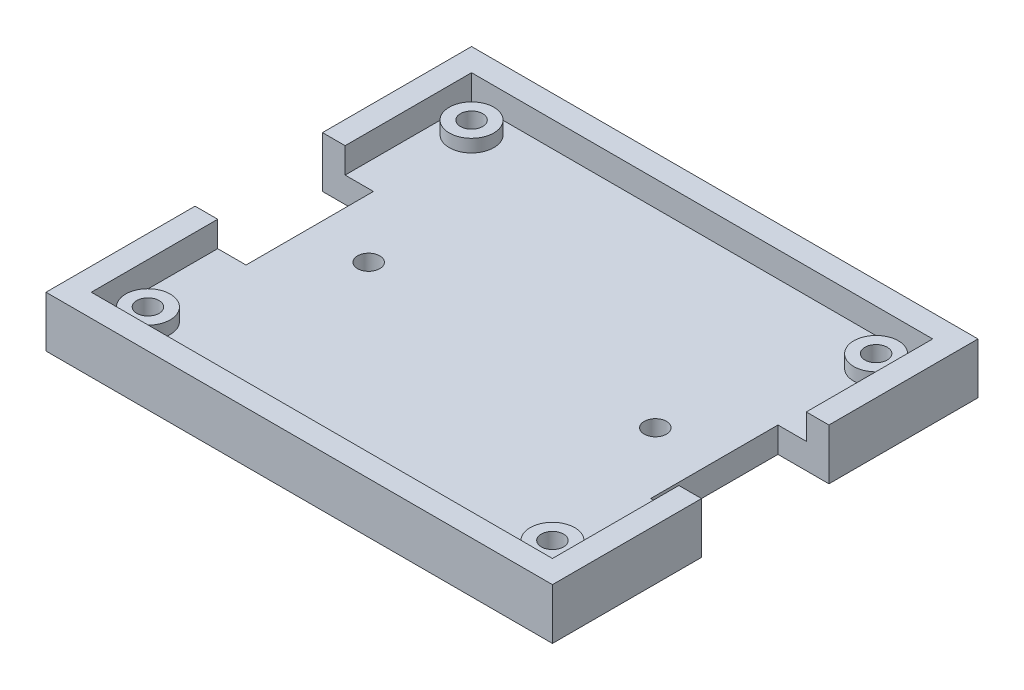
from build123d import *

# Parameters (mm, degrees)
SKETCH1_R           = 1.75
SKETCH1_R_2         = 3.5
BOSS_EXTRUDE1_DEPTH = 4
BOSS_EXTRUDE2_DEPTH = 8
SKETCH1_4_R         = 3.5
SKETCH1_4_R_2       = 1.75
BOSS_EXTRUDE3_DEPTH = 6


with BuildPart() as part:
    # Sketch1 → Boss-Extrude1 (new body)
    with BuildSketch(Plane(origin=(0, 0, 0), x_dir=(1, 0, 0), z_dir=(0, 1, 0))):
        Polygon((31.75, -10), (31.75, 10), (36.195, 10), (36.195, 29.845), (-36.195, 29.845), (-36.195, 10), (-31.75, 10), (-31.75, -10), (-36.195, -10), (-36.195, -29.845), (36.195, -29.845), (36.195, -10), align=None)
        with Locations((-22.5, 0)):
            Circle(SKETCH1_R, mode=Mode.SUBTRACT)
        with Locations((22.5, 0)):
            Circle(SKETCH1_R, mode=Mode.SUBTRACT)
        with Locations((31.75, -25.4)):
            Circle(SKETCH1_R_2, mode=Mode.SUBTRACT)
        with Locations((-31.75, -25.4)):
            Circle(SKETCH1_R_2, mode=Mode.SUBTRACT)
        with Locations((-31.75, 25.4)):
            Circle(SKETCH1_R_2, mode=Mode.SUBTRACT)
        with Locations((31.75, 25.4)):
            Circle(SKETCH1_R_2, mode=Mode.SUBTRACT)
    extrude(amount=BOSS_EXTRUDE1_DEPTH)

    # Sketch1_3 → Boss-Extrude2 (add)
    with BuildSketch(Plane(origin=(0, 0, 0), x_dir=(1, 0, 0), z_dir=(0, 1, 0))):
        Polygon((39.75, -33.4), (39.75, -10), (36.195, -10), (36.195, -29.845), (-36.195, -29.845), (-36.195, -10), (-39.75, -10), (-39.75, -33.4), align=None)
        Polygon((36.195, 10), (39.75, 10), (39.75, 33.4), (-39.75, 33.4), (-39.75, 10), (-36.195, 10), (-36.195, 29.845), (36.195, 29.845), align=None)
    extrude(amount=BOSS_EXTRUDE2_DEPTH)

    # Sketch1_4 → Boss-Extrude3 (add)
    # profile 1 of 4: a face of its own
    with BuildSketch(Plane(origin=(0, 0, 0), x_dir=(1, 0, 0), z_dir=(0, 1, 0))):
        with Locations((31.75, -25.4)):
            Circle(SKETCH1_4_R)
        with Locations((31.75, -25.4)):
            Circle(SKETCH1_4_R_2, mode=Mode.SUBTRACT)
    # profile 2 of 4: a face of its own
    with BuildSketch(Plane(origin=(0, 0, 0), x_dir=(1, 0, 0), z_dir=(0, 1, 0))):
        with Locations((31.75, 25.4)):
            Circle(SKETCH1_4_R)
        with Locations((31.75, 25.4)):
            Circle(SKETCH1_4_R_2, mode=Mode.SUBTRACT)
    # profile 3 of 4: a face of its own
    with BuildSketch(Plane(origin=(0, 0, 0), x_dir=(1, 0, 0), z_dir=(0, 1, 0))):
        with Locations((-31.75, -25.4)):
            Circle(SKETCH1_4_R)
        with Locations((-31.75, -25.4)):
            Circle(SKETCH1_4_R_2, mode=Mode.SUBTRACT)
    # profile 4 of 4: a face of its own
    with BuildSketch(Plane(origin=(0, 0, 0), x_dir=(1, 0, 0), z_dir=(0, 1, 0))):
        with Locations((-31.75, 25.4)):
            Circle(SKETCH1_4_R)
        with Locations((-31.75, 25.4)):
            Circle(SKETCH1_4_R_2, mode=Mode.SUBTRACT)
    extrude(amount=BOSS_EXTRUDE3_DEPTH)


solid = part.part
